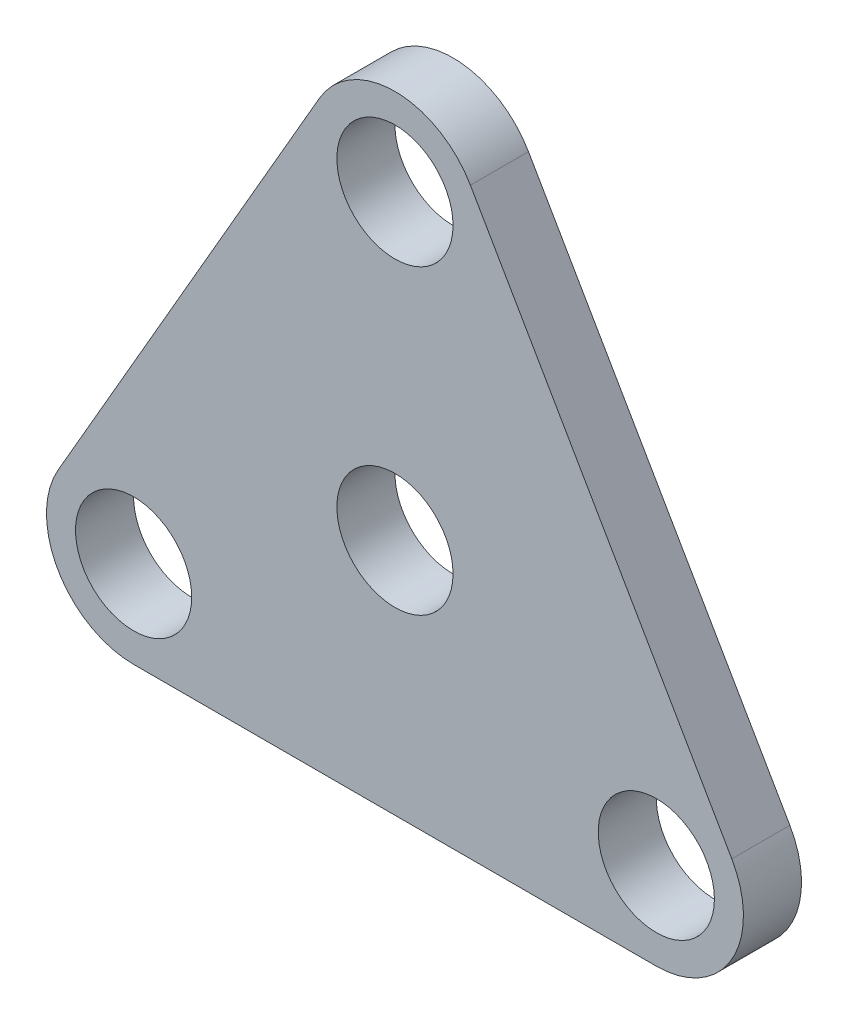
from build123d import *

# Parameters (mm, degrees)
SKETCH1_R           = 6.35
BOSS_EXTRUDE1_DEPTH = 6.35


with BuildPart() as part:
    # Sketch1 → Boss-Extrude1 (new body)
    with BuildSketch(Plane.XY):
        with BuildLine():
            Line((-8.248891971, 37.758067884), (-36.823891971, -11.735283942))
            ThreePointArc((-36.823891971, -11.735283942), (-36.823891971, -21.260283942), (-28.575, -26.022783942))
            Line((-28.575, -26.022783942), (28.575, -26.022783942))
            ThreePointArc((28.575, -26.022783942), (36.823891971, -21.260283942), (36.823891971, -11.735283942))
            Line((36.823891971, -11.735283942), (8.248891971, 37.758067884))
            ThreePointArc((8.248891971, 37.758067884), (0, 42.520567884), (-8.248891971, 37.758067884))
        make_face()
        Circle(SKETCH1_R, mode=Mode.SUBTRACT)
        with Locations((-28.575, -16.497783942)):
            Circle(SKETCH1_R, mode=Mode.SUBTRACT)
        with Locations((0, 32.995567884)):
            Circle(SKETCH1_R, mode=Mode.SUBTRACT)
        with Locations((28.575, -16.497783942)):
            Circle(SKETCH1_R, mode=Mode.SUBTRACT)
    extrude(amount=BOSS_EXTRUDE1_DEPTH)


solid = part.part
